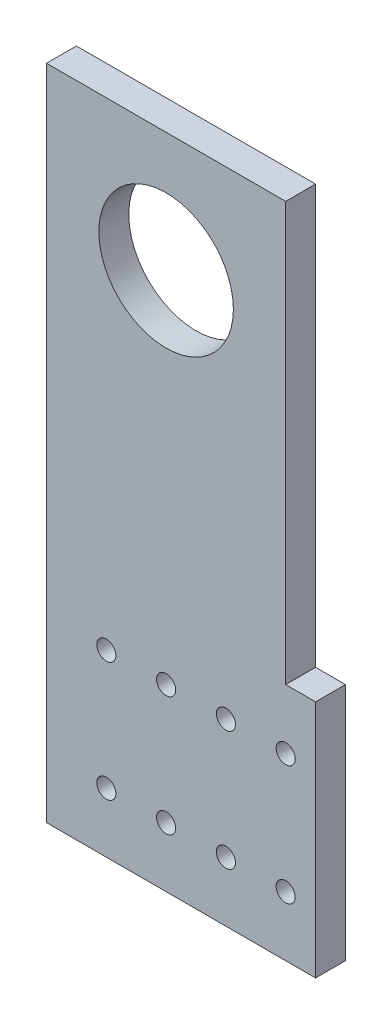
from build123d import *

# Parameters (mm, degrees)
BOSS_EXTRUDE1_DEPTH = 6.35
SKETCH3_R           = 14.2875
SKETCH3_R_2         = 2.032
CUT_EXTRUDE1_DEPTH  = 6.35


with BuildPart() as part:
    # Sketch2 → Boss-Extrude1 (new body)
    with BuildSketch(Plane.XY):
        Polygon((-125.79203122, -159.641560721), (-74.99203122, -159.641560721), (-68.64203122, -159.641560721), (-68.64203122, -108.841560721), (-74.99203122, -108.841560721), (-74.99203122, -19.941560721), (-125.79203122, -19.941560721), align=None)
    extrude(amount=BOSS_EXTRUDE1_DEPTH)

    # Sketch3 → Cut-Extrude1 (cut)
    with BuildSketch(Plane.XY.offset(6.35)):
        with Locations((-100.39203122, -45.351567892)):
            Circle(SKETCH3_R)
        with Locations((-87.69203122, -146.941560721)):
            Circle(SKETCH3_R_2)
        with Locations((-113.09203122, -146.941560721)):
            Circle(SKETCH3_R_2)
        with Locations((-100.39203122, -146.941560721)):
            Circle(SKETCH3_R_2)
        with Locations((-74.99203122, -146.941560721)):
            Circle(SKETCH3_R_2)
        with Locations((-113.09203122, -121.541560721)):
            Circle(SKETCH3_R_2)
        with Locations((-87.69203122, -121.541560721)):
            Circle(SKETCH3_R_2)
        with Locations((-74.99203122, -121.541560721)):
            Circle(SKETCH3_R_2)
        with Locations((-100.39203122, -121.541560721)):
            Circle(SKETCH3_R_2)
    extrude(amount=-CUT_EXTRUDE1_DEPTH, mode=Mode.SUBTRACT)


solid = part.part
